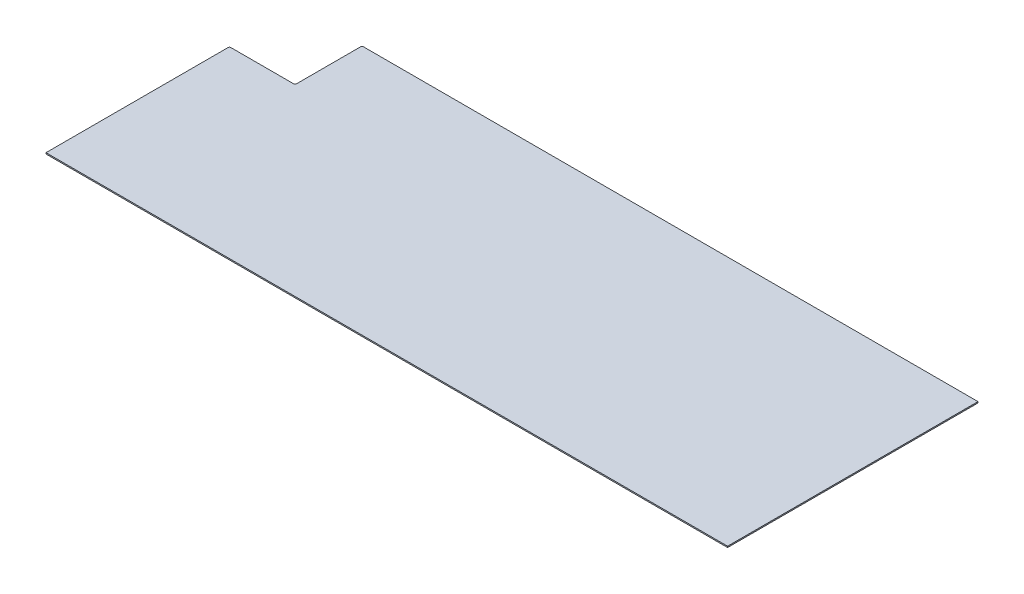
from build123d import *

# Parameters (mm, degrees)
BOSS_EXTRUDE1_DEPTH = 2.921


with BuildPart() as part:
    # Sketch1 → Boss-Extrude1 (new body)
    with BuildSketch(Plane(origin=(0, 0, 0), x_dir=(1, 0, 0), z_dir=(0, 1, 0))):
        with BuildLine():
            Line((0, 0), (1616.075, 0))
            Line((1616.075, 0), (1616.075, 593.725))
            Line((1616.075, 593.725), (158.75, 593.725))
            ThreePointArc((158.75, 593.725), (156.50493597, 592.79506403), (155.575, 590.55))
            Line((155.575, 590.55), (155.575, 438.15))
            ThreePointArc((155.575, 438.15), (154.64506403, 435.90493597), (152.4, 434.975))
            Line((152.4, 434.975), (3.175, 434.975))
            ThreePointArc((3.175, 434.975), (0.92993597, 434.04506403), (0, 431.8))
            Line((0, 431.8), (0, 0))
        make_face()
    extrude(amount=BOSS_EXTRUDE1_DEPTH)


solid = part.part
